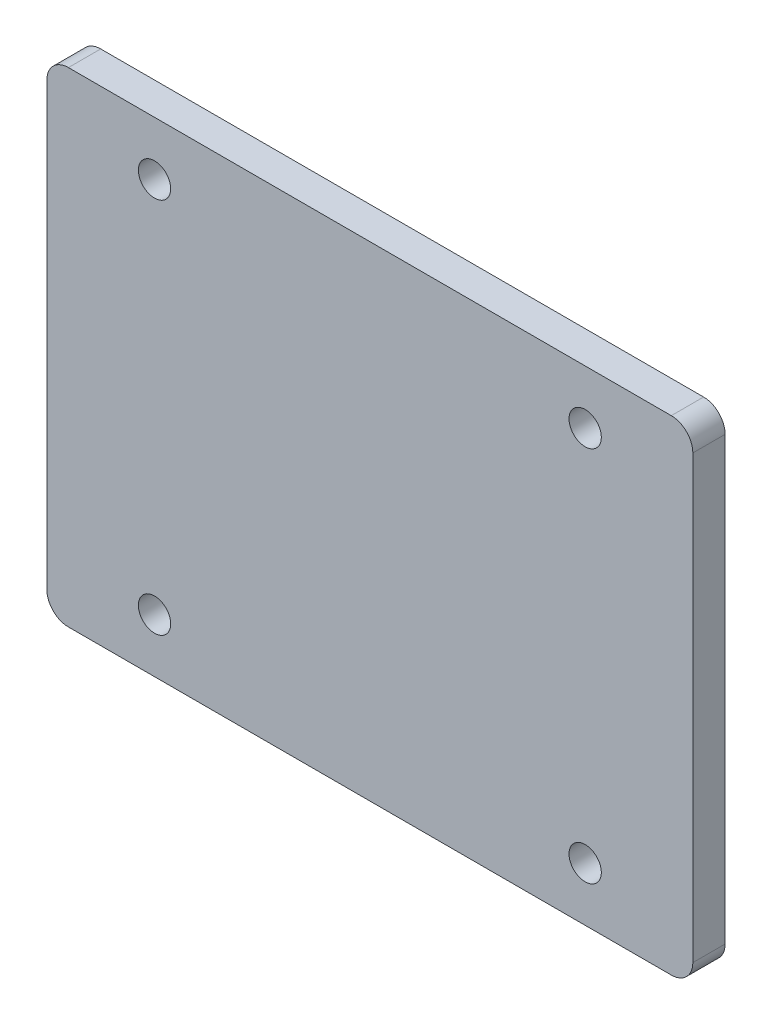
from build123d import *

# Parameters (mm, degrees)
SKETCH_2_W          = 60
SKETCH_2_H          = 45
EXTRUDE_1_DEPTH     = 3
FILLET_3_R          = 2
SKETCH_4_R          = 1.5
CUT_EXTRUDE_1_DEPTH = 4


with BuildPart() as part:
    # ｽｹｯﾁ2 → ﾎﾞｽ - 押し出し1 (new body)
    with BuildSketch(Plane.XY):
        with Locations((30, 22.5)):
            Rectangle(SKETCH_2_W, SKETCH_2_H)
    extrude(amount=EXTRUDE_1_DEPTH)

    # ﾌｨﾚｯﾄ3
    fillet_3_edges = [part.edges().sort_by_distance(p)[0] for p in [
        (0, 45, 1.5),
        (60, 45, 1.5),
        (60, 0, 1.5),
        (0, 0, 1.5),
    ]]
    fillet(fillet_3_edges, radius=FILLET_3_R)

    # ｽｹｯﾁ4 → ｶｯﾄ - 押し出し1 (cut, through all)
    with BuildSketch(Plane.XY.offset(3)):
        with Locations((10, 40)):
            Circle(SKETCH_4_R)
        with Locations((50, 40)):
            Circle(SKETCH_4_R)
        with Locations((10, 5)):
            Circle(SKETCH_4_R)
        with Locations((50, 5)):
            Circle(SKETCH_4_R)
    extrude(amount=-CUT_EXTRUDE_1_DEPTH, mode=Mode.SUBTRACT)


solid = part.part
